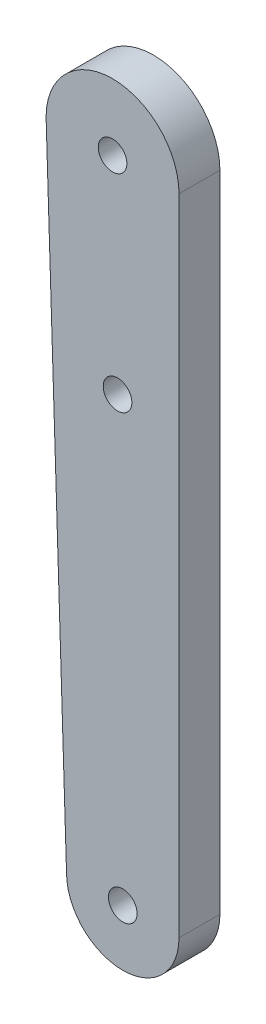
from build123d import *

# Parameters (mm, degrees)
SKETCH1_R           = 1.4
BOSS_EXTRUDE1_DEPTH = 4


with BuildPart() as part:
    # Sketch1 → Boss-Extrude1 (new body)
    with BuildSketch(Plane.XY):
        with BuildLine():
            Line((-0.000688459, 1.993317296), (-0.000688459, 65.016091721))
            ThreePointArc((-0.000688459, 65.016091721), (-6.500688459, 71.516091721), (-13.000688459, 65.016091721))
            Line((-13.000688459, 65.016091721), (-11.000688459, 1.993317296))
            ThreePointArc((-11.000688459, 1.993317296), (-5.500688459, -3.506682704), (-0.000688459, 1.993317296))
        make_face()
        with Locations((-6.500688459, 65.016091721)):
            Circle(SKETCH1_R, mode=Mode.SUBTRACT)
        with Locations((-5.500688459, 1.993317296)):
            Circle(SKETCH1_R, mode=Mode.SUBTRACT)
        with Locations((-6.012756351, 45.016091721)):
            Circle(SKETCH1_R, mode=Mode.SUBTRACT)
    extrude(amount=BOSS_EXTRUDE1_DEPTH)


solid = part.part
